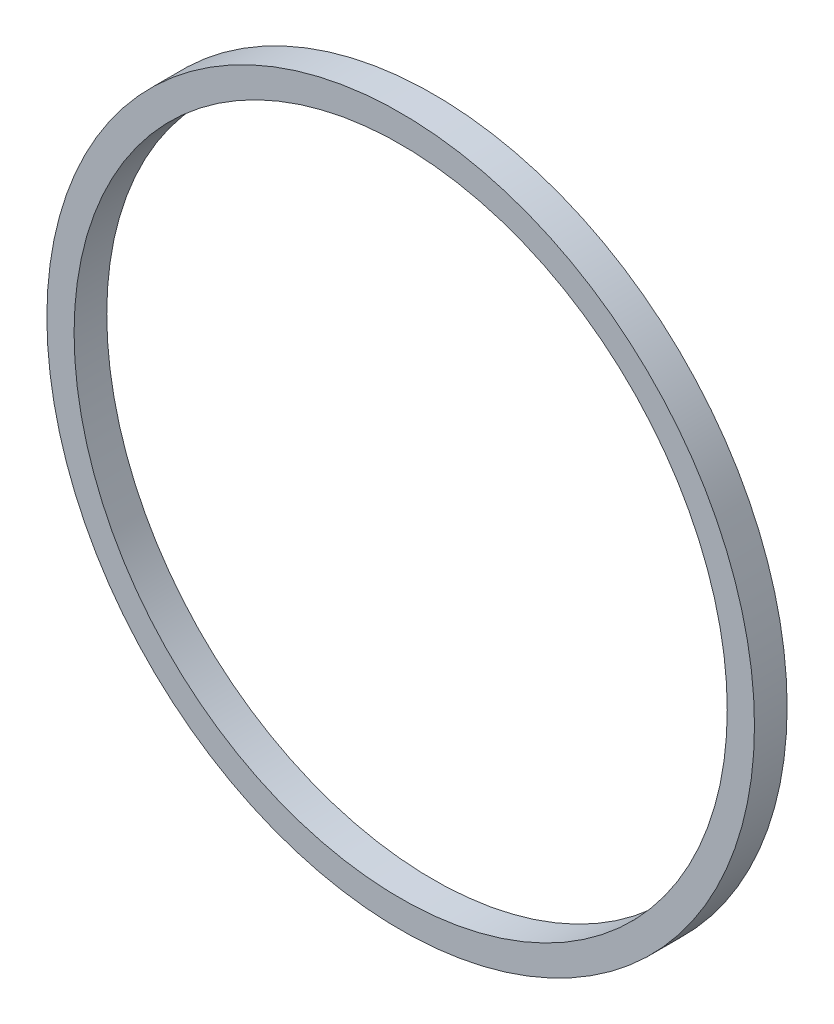
from build123d import *

# Parameters (mm, degrees)
SKETCH1_R           = 65
BOSS_EXTRUDE1_DEPTH = 6
SKETCH2_R           = 60
CUT_EXTRUDE1_DEPTH  = 7


with BuildPart() as part:
    # Sketch1 → Boss-Extrude1 (new body)
    with BuildSketch(Plane.XY):
        Circle(SKETCH1_R)
    extrude(amount=BOSS_EXTRUDE1_DEPTH)

    # Sketch2 → Cut-Extrude1 (cut, through all)
    with BuildSketch(Plane(origin=(0, 0, 0), x_dir=(-1, 0, 0), z_dir=(0, 0, -1))):
        Circle(SKETCH2_R)
    extrude(amount=-CUT_EXTRUDE1_DEPTH, mode=Mode.SUBTRACT)


solid = part.part
